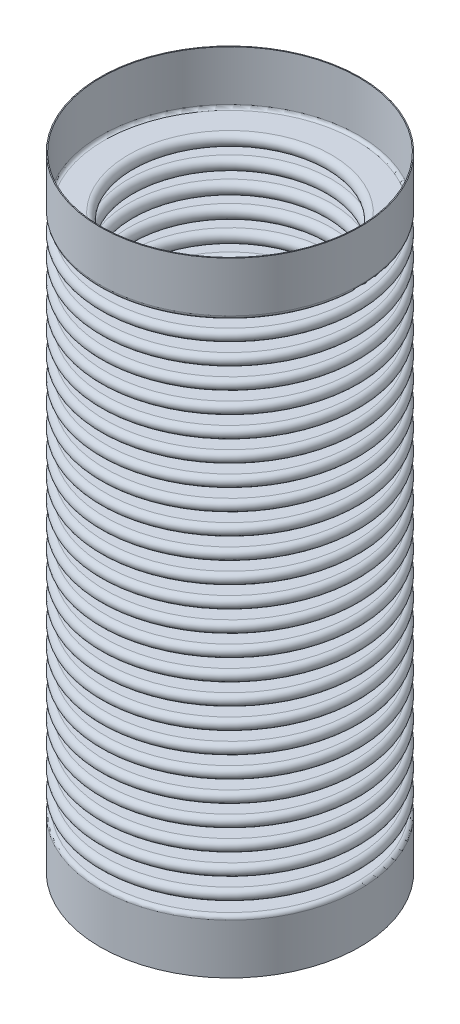
from build123d import *
from build123d.topology import SkipClean

# Parameters (mm, degrees)
LPATTERN1_COUNT = 24
LPATTERN1_PITCH = 2.056905529


with BuildPart() as part:
    # Sketch1 → Revolve-Thin1 (revolve)
    with BuildSketch(Plane(origin=(0, 0, 0), x_dir=(0, 0, -1), z_dir=(1, 0, 0))):
        with BuildLine():
            ThreePointArc((9.398, 1.028453074), (9.548613466, 0.664840003), (9.912226537, 0.514226537))
            Line((9.912226537, 0.514226537), (12.185773463, 0.514226537))
            ThreePointArc((12.185773463, 0.514226537), (12.7, 0), (12.185773463, -0.514226537))
            Line((12.185773463, -0.514226537), (9.912226537, -0.514226537))
            ThreePointArc((9.912226537, -0.514226537), (9.548613466, -0.664840003), (9.398, -1.028453074))
            Line((9.398, -1.028453074), (9.3091, -1.028453074))
            ThreePointArc((9.3091, -1.028453074), (9.485751673, -0.60197821), (9.912226537, -0.425326537))
            Line((9.912226537, -0.425326537), (12.185773463, -0.425326537))
            ThreePointArc((12.185773463, -0.425326537), (12.6111, 0), (12.185773463, 0.425326537))
            Line((12.185773463, 0.425326537), (9.912226537, 0.425326537))
            ThreePointArc((9.912226537, 0.425326537), (9.485751673, 0.60197821), (9.3091, 1.028453074))
            Line((9.3091, 1.028453074), (9.398, 1.028453074))
        make_face()
    revolve_thin1 = revolve(axis=Axis((0, 0, 0), (0, 1, 0)))

    # LPattern1: Revolve-Thin1 ×24
    with Locations(*[(0, -i * LPATTERN1_PITCH, 0) for i in range(1, LPATTERN1_COUNT)]):
        add(revolve_thin1)

    # Sketch9 → Revolve-Thin4 (revolve)
    with SkipClean():  # keep this step's faces unmerged: merging them makes the solid invalid here
        with BuildSketch(Plane(origin=(0, 0, 0), x_dir=(0, 0, -1), z_dir=(1, 0, 0))):
            with BuildLine():
                ThreePointArc((9.398, 1.028453074), (9.548613466, 1.392066145), (9.912226537, 1.542679611))
                Line((9.912226537, 1.542679611), (12.32, 1.542679611))
                ThreePointArc((12.32, 1.542679611), (12.588700577, 1.653979034), (12.7, 1.922679611))
                Line((12.7, 1.922679611), (12.7, 6.812179611))
                Line((12.7, 6.812179611), (12.6111, 6.812179611))
                Line((12.6111, 6.812179611), (12.6111, 1.922679611))
                ThreePointArc((12.6111, 1.922679611), (12.525838784, 1.716840827), (12.32, 1.631579611))
                Line((12.32, 1.631579611), (9.912226537, 1.631579611))
                ThreePointArc((9.912226537, 1.631579611), (9.485751673, 1.454927938), (9.3091, 1.028453074))
                Line((9.3091, 1.028453074), (9.398, 1.028453074))
            make_face()
        revolve_thin4 = revolve(axis=Axis((0, 0, 0), (0, 1, 0)))

    # Mirror1: Revolve-Thin4 across plane
    with SkipClean():  # keep this step's faces unmerged: merging them makes the solid invalid here
        add(revolve_thin4.mirror(Plane.ZX.offset(-23.654413584)))


solid = part.part
